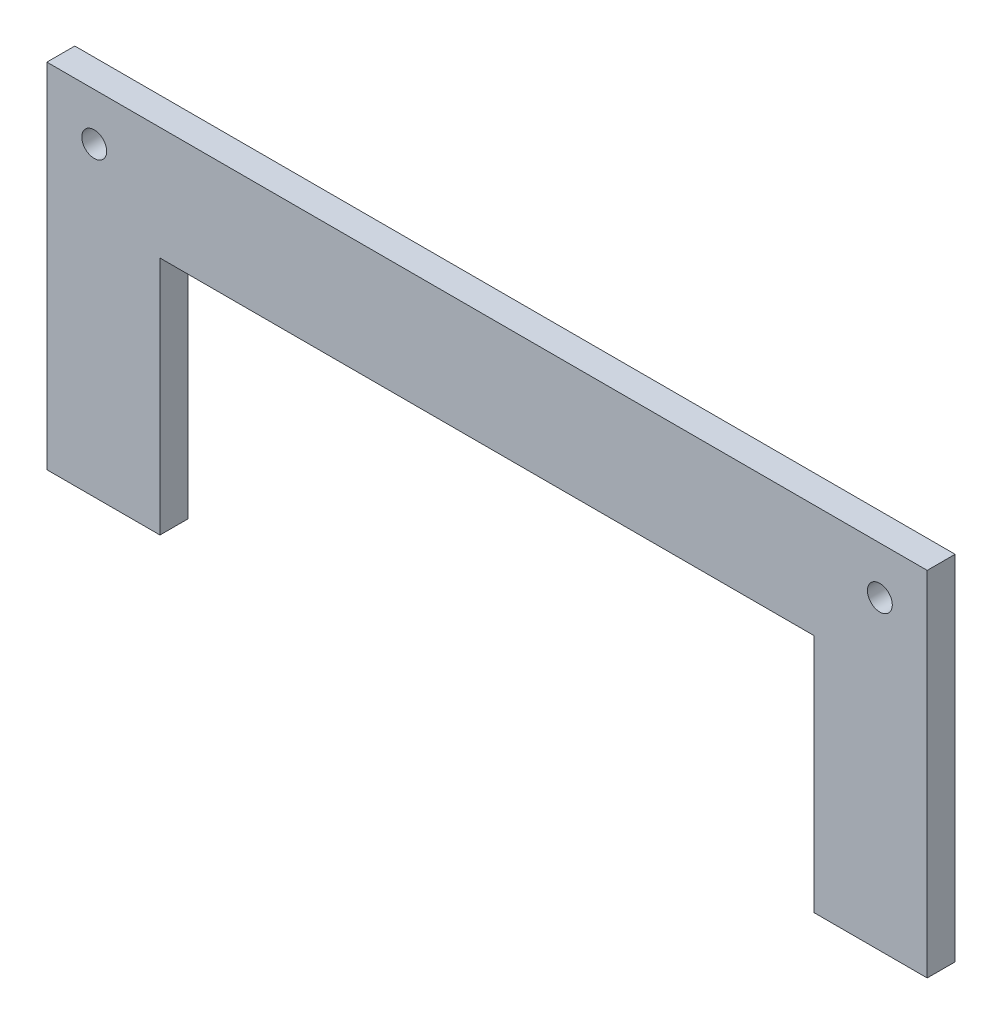
from build123d import *

# Parameters (mm, degrees)
SKETCH1_R           = 1.415
BOSS_EXTRUDE1_DEPTH = 3.175


with BuildPart() as part:
    # Sketch1 → Boss-Extrude1 (new body)
    with BuildSketch(Plane.XY):
        Polygon((50.085, -40.085), (50.085, 0.085), (-50.085, 0.085), (-50.085, -40.085), (-37.215, -40.085), (-37.215, -12.785), (37.215, -12.785), (37.215, -40.085), align=None)
        with Locations((-44.696699141, -5.303300859)):
            Circle(SKETCH1_R, mode=Mode.SUBTRACT)
        with Locations((44.696699141, -5.303300859)):
            Circle(SKETCH1_R, mode=Mode.SUBTRACT)
    extrude(amount=BOSS_EXTRUDE1_DEPTH)


solid = part.part
